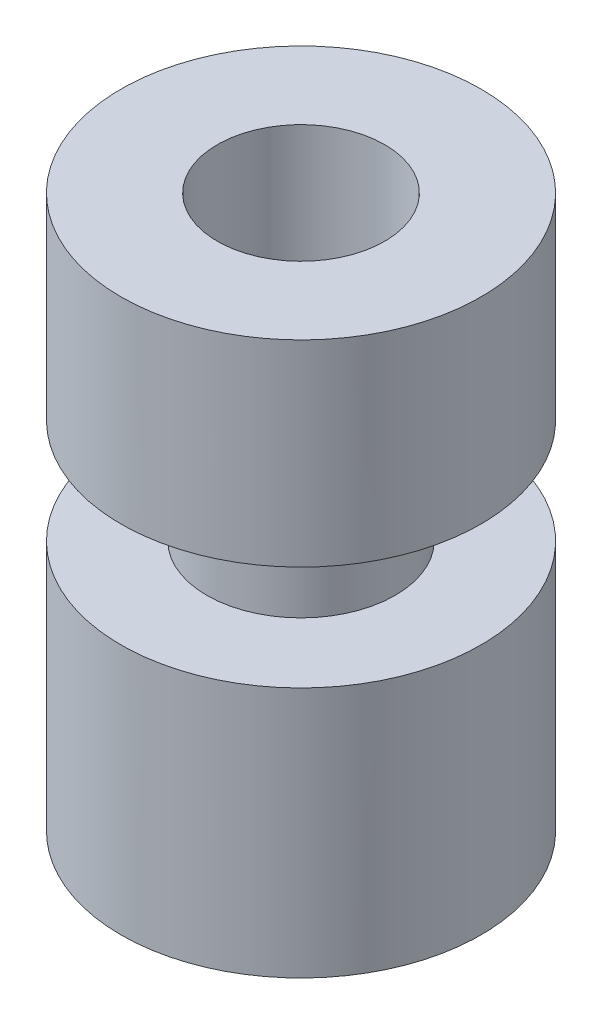
from build123d import *

# Parameters (mm, degrees)
SKETCH1_R           = 2.15
BOSS_EXTRUDE1_DEPTH = 6.6
SKETCH2_R           = 1
CUT_EXTRUDE1_DEPTH  = 7.6
SKETCH3_R           = 2.15
SKETCH3_R_2         = 1.125
CUT_EXTRUDE2_DEPTH  = 1.25


with BuildPart() as part:
    # Sketch1 → Boss-Extrude1 (new body)
    with BuildSketch(Plane(origin=(0, 0, 0), x_dir=(1, 0, 0), z_dir=(0, 1, 0))):
        Circle(SKETCH1_R)
    extrude(amount=BOSS_EXTRUDE1_DEPTH)

    # Sketch2 → Cut-Extrude1 (cut, through all)
    with BuildSketch(Plane.XZ):
        Circle(SKETCH2_R)
    extrude(amount=-CUT_EXTRUDE1_DEPTH, mode=Mode.SUBTRACT)

    # Sketch3 → Cut-Extrude2 (cut)
    with BuildSketch(Plane(origin=(0, 4.25, 0), x_dir=(-1, 0, 0), z_dir=(0, -1, 0))):
        Circle(SKETCH3_R)
        Circle(SKETCH3_R_2, mode=Mode.SUBTRACT)
    extrude(amount=CUT_EXTRUDE2_DEPTH, mode=Mode.SUBTRACT)


solid = part.part
